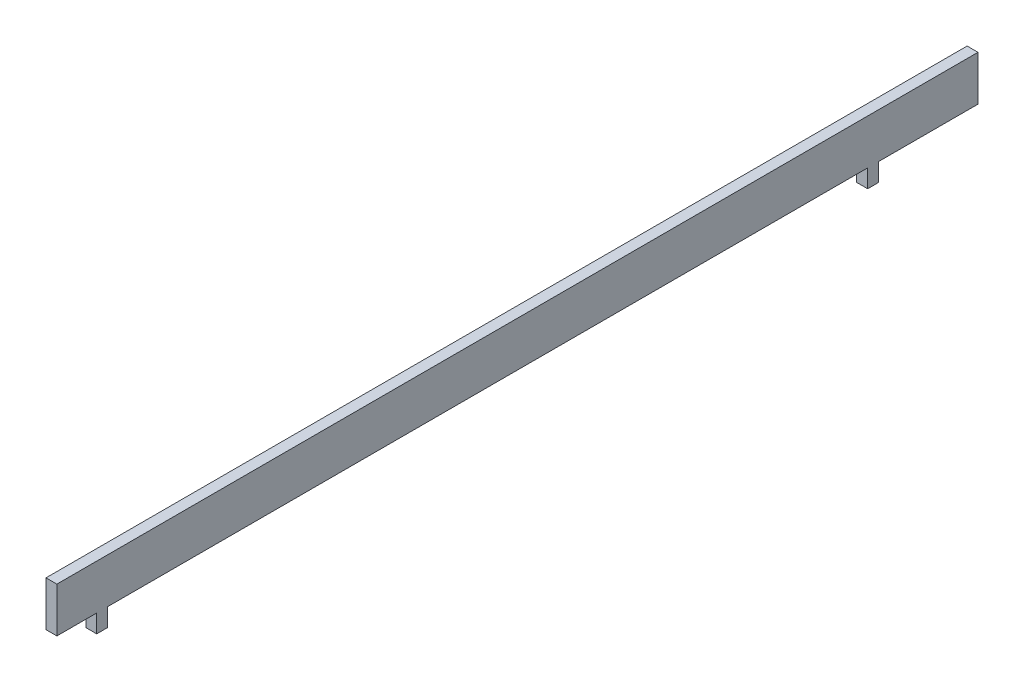
from build123d import *
from build123d.topology import SkipClean

# Parameters (mm, degrees)
SKETCH1_W           = 254.5
SKETCH1_H           = 20
BOSS_EXTRUDE1_DEPTH = 1.5
CUT_REVOLVE1_ANGLE  = 360


with BuildPart() as part:
    # Sketch1 → Boss-Extrude1 (new body, symmetric)
    with BuildSketch(Plane(origin=(0, 0, 0), x_dir=(0, 0, -1), z_dir=(1, 0, 0))):
        with Locations((447.25, 86)):
            Rectangle(SKETCH1_W, SKETCH1_H)
    extrude(amount=BOSS_EXTRUDE1_DEPTH, both=True)

    # Sketch2 → Cut-Revolve1 (revolve, symmetric, cut)
    with SkipClean():  # keep this step's faces unmerged: merging them makes the solid invalid here
        with BuildSketch(Plane(origin=(0, 0, 0), x_dir=(0, 0, -1), z_dir=(1, 0, 0))) as cut_revolve1_sk:
            Polygon((320, 83.6), (331, 83.6), (331, 78.6), (334, 78.6), (334, 83.6), (544, 83.6), (544, 78.6), (547, 78.6), (547, 83.6), (574.5, 83.6), (574.5, 65.235756371), (320, 65.235756371), align=None)
        revolve(axis=Axis((0, 0, 0), (0, 0, -1)), revolution_arc=CUT_REVOLVE1_ANGLE / 2, mode=Mode.SUBTRACT)
        revolve(cut_revolve1_sk.sketch, axis=Axis((0, 0, 0), (0, 0, 1)), revolution_arc=CUT_REVOLVE1_ANGLE / 2, mode=Mode.SUBTRACT)


solid = part.part
